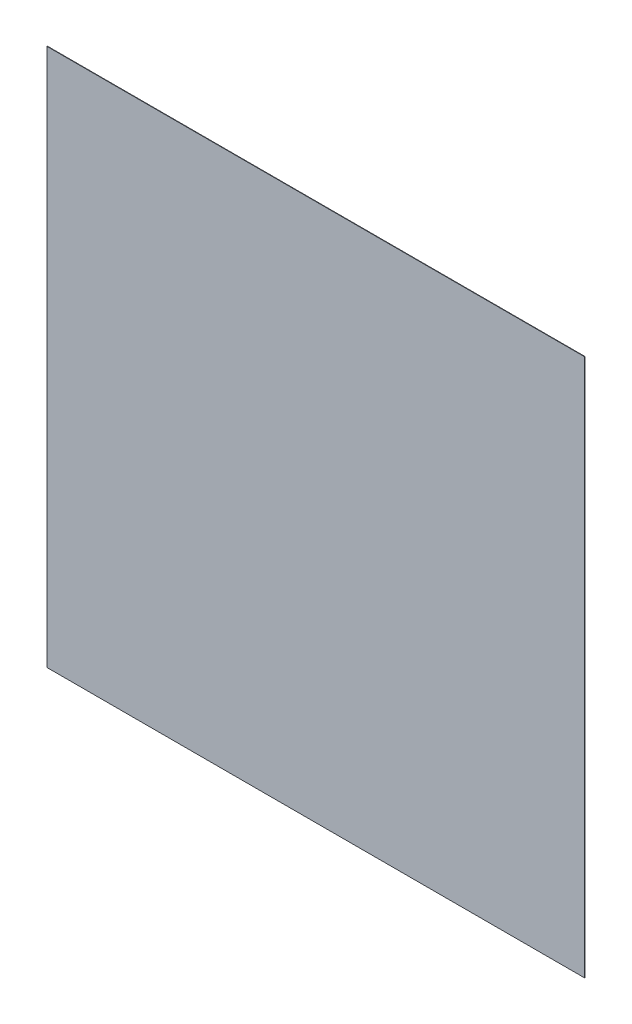
from build123d import *

# Parameters (mm, degrees)
SKETCH1_W           = 3048
SKETCH1_H           = 3048
BOSS_EXTRUDE1_DEPTH = 2.54


with BuildPart() as part:
    # Sketch1 → Boss-Extrude1 (new body)
    with BuildSketch(Plane.XY):
        Rectangle(SKETCH1_W, SKETCH1_H)
    extrude(amount=BOSS_EXTRUDE1_DEPTH)


solid = part.part
